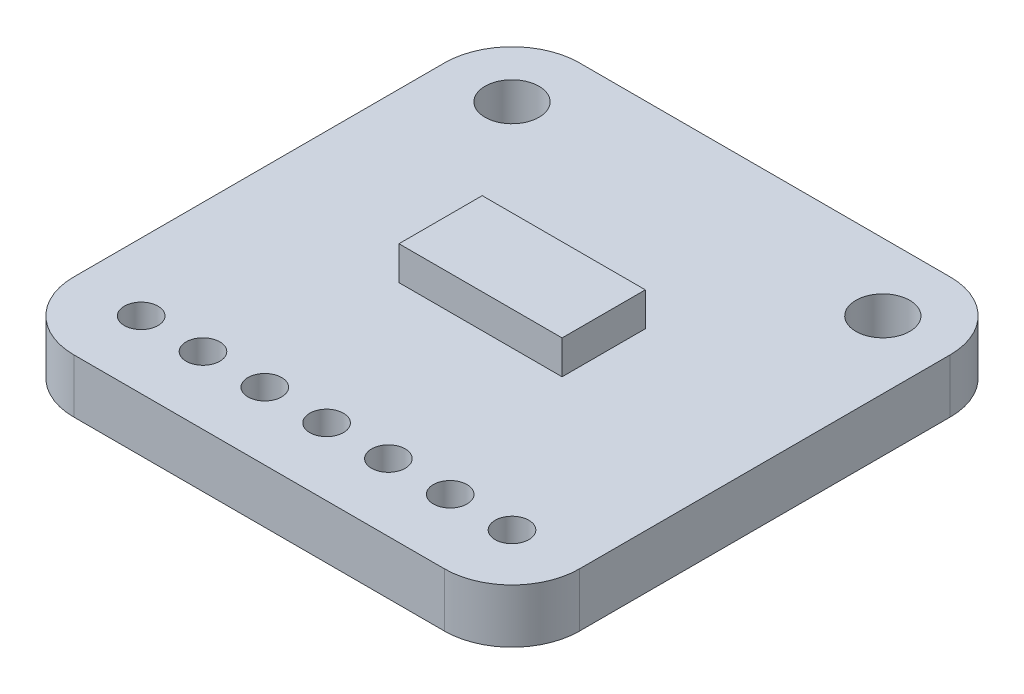
from build123d import *

# Parameters (mm, degrees)
BOSS_EXTRUDE1_DEPTH = 2.032
SKETCH2_R           = 1.016
SKETCH2_R_2         = 0.635
CUT_EXTRUDE1_DEPTH  = 3.032
SKETCH3_W           = 6.145312949
SKETCH3_H           = 3.136404534
BOSS_EXTRUDE2_DEPTH = 1.27


with BuildPart() as part:
    # Sketch1 → Boss-Extrude1 (new body)
    with BuildSketch(Plane(origin=(0, 0, 0), x_dir=(1, 0, 0), z_dir=(0, 1, 0))):
        with BuildLine():
            Line((0, 2.54), (0, 16.51))
            ThreePointArc((0, 16.51), (0.743948776, 18.306051224), (2.54, 19.05))
            Line((2.54, 19.05), (16.51, 19.05))
            ThreePointArc((16.51, 19.05), (18.306051224, 18.306051224), (19.05, 16.51))
            Line((19.05, 16.51), (19.05, 2.54))
            ThreePointArc((19.05, 2.54), (18.306051224, 0.743948776), (16.51, 0))
            Line((16.51, 0), (2.54, 0))
            ThreePointArc((2.54, 0), (0.743948776, 0.743948776), (0, 2.54))
        make_face()
    extrude(amount=BOSS_EXTRUDE1_DEPTH)

    # Sketch2 → Cut-Extrude1 (cut, through all)
    with BuildSketch(Plane(origin=(0, 2.032, 0), x_dir=(1, 0, 0), z_dir=(0, 1, 0))):
        with Locations((2.54, 16.51)):
            Circle(SKETCH2_R)
        with Locations((16.51, 16.51)):
            Circle(SKETCH2_R)
        with Locations((2.54, 2.54)):
            Circle(SKETCH2_R_2)
        with Locations((4.868333333, 2.54)):
            Circle(SKETCH2_R_2)
        with Locations((7.196666667, 2.54)):
            Circle(SKETCH2_R_2)
        with Locations((9.525, 2.54)):
            Circle(SKETCH2_R_2)
        with Locations((11.853333333, 2.54)):
            Circle(SKETCH2_R_2)
        with Locations((14.181666667, 2.54)):
            Circle(SKETCH2_R_2)
        with Locations((16.51, 2.54)):
            Circle(SKETCH2_R_2)
    extrude(amount=-CUT_EXTRUDE1_DEPTH, mode=Mode.SUBTRACT)

    # Sketch3 → Boss-Extrude2 (add)
    with BuildSketch(Plane(origin=(0, 2.032, 0), x_dir=(1, 0, 0), z_dir=(0, 1, 0))):
        with Locations((9.384754269, 10.047734089)):
            Rectangle(SKETCH3_W, SKETCH3_H)
    extrude(amount=BOSS_EXTRUDE2_DEPTH)


solid = part.part
